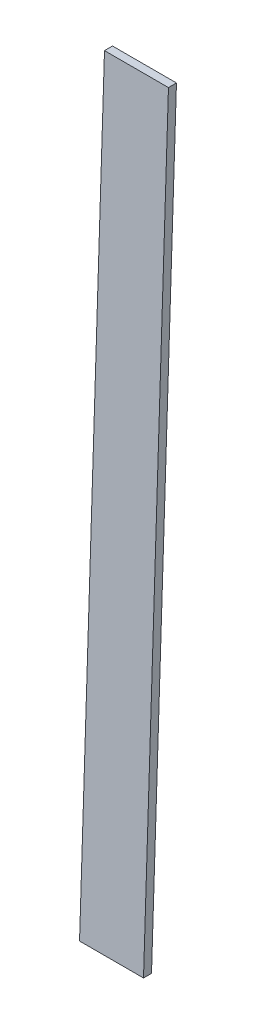
from build123d import *

# Parameters (mm, degrees)
SKETCH2_W = 25.4
SKETCH2_H = 3.175
SKETCH1_W = 25.4
SKETCH1_H = 3.175


with BuildPart() as part:
    # Sketch2 → Loft1 section 0
    with BuildSketch(Plane(origin=(0, 301.244, 0), x_dir=(1, 0, 0), z_dir=(0, 1, 0))):
        with Locations((12.7, 11.4935)):
            Rectangle(SKETCH2_W, SKETCH2_H)
    # Sketch1 → Loft1 section 1
    with BuildSketch(Plane(origin=(0, 0, 0), x_dir=(1, 0, 0), z_dir=(0, 1, 0))):
        with Locations((12.7, 1.5875)):
            Rectangle(SKETCH1_W, SKETCH1_H)
    loft()


solid = part.part
